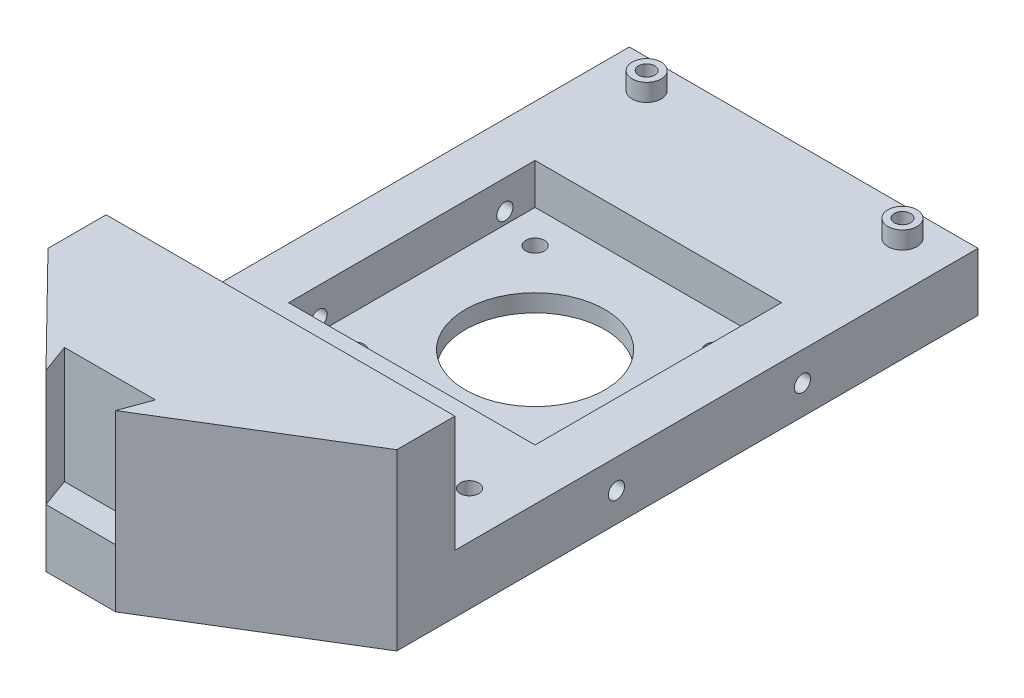
from build123d import *

# Parameters (mm, degrees)
EXTRUDE_1_DEPTH             = 30
SKETCH_2_W                  = 90
SKETCH_2_H                  = 20
CUT_EXTRUDE_1_DEPTH         = 61
SKETCH_3_W                  = 42.4
SKETCH_3_H                  = 42.4
CUT_EXTRUDE_2_DEPTH         = 7
SKETCH_4_W                  = 2.5
SKETCH_4_H                  = 3
SKETCH_5_W                  = 2.5
SKETCH_5_H                  = 3
HOLE_WIZARD_24_0_24_1_D     = 24
HOLE_WIZARD_24_0_24_1_DEPTH = 3
HOLE_WIZARD_3_2_3_2_1_D     = 3.2
HOLE_WIZARD_3_2_3_2_1_DEPTH = 3
HOLE_WIZARD_2_8_2_8_1_D     = 2.8
HOLE_WIZARD_2_8_2_8_1_DEPTH = 13
HOLE_WIZARD_3_2_3_2_2_D     = 3.2
HOLE_WIZARD_3_2_3_2_2_DEPTH = 10
HOLE_WIZARD_2_8_2_8_2_D     = 2.8
HOLE_WIZARD_2_8_2_8_2_DEPTH = 8.8
HOLE_WIZARD_2_8_2_8_3_D     = 2.8
HOLE_WIZARD_2_8_2_8_3_DEPTH = 8.8
EXTRUDE_2_DEPTH             = 10


with BuildPart() as part:
    # 草图1 → 凸台-拉伸1 (new body)
    with BuildSketch(Plane(origin=(0, 30, 0), x_dir=(1, 0, 0), z_dir=(0, 1, 0))):
        Polygon((-53.759164819, 38.577872891), (-53.759164819, -61.422127109), (-35.759164819, -79.767511878), (-37.57901599, -74.767511878), (-21.939313647, -74.767511878), (-23.759164819, -79.767511878), (6.240835181, -61.422127109), (6.240835181, 38.577872891), align=None)
    extrude(amount=-EXTRUDE_1_DEPTH)

    # 草图2 → 切除-拉伸1 (cut, through all)
    with BuildSketch(Plane.ZY.offset(53.759164819)):
        with Locations((6.422127109, 20)):
            Rectangle(SKETCH_2_W, SKETCH_2_H)
    extrude(amount=-CUT_EXTRUDE_1_DEPTH, mode=Mode.SUBTRACT)

    # 草图3 → 切除-拉伸2 (cut)
    with BuildSketch(Plane(origin=(0, 10, 0), x_dir=(-1, 0, 0), z_dir=(0, 1, 0))):
        with Locations((23.759164819, 7.622127109)):
            Rectangle(SKETCH_3_W, SKETCH_3_H)
    extrude(amount=-CUT_EXTRUDE_2_DEPTH, mode=Mode.SUBTRACT)

    # 草图4 → 旋转1 (revolve)
    with BuildSketch(Plane.XY.offset(-33.577872891)):
        with Locations((-44.509164819, 11.5)):
            Rectangle(SKETCH_4_W, SKETCH_4_H)
    revolve(axis=Axis((-45.759164819, 13, -33.577872891), (0, -1, 0)))

    # 草图5 → 旋转2 (revolve)
    with BuildSketch(Plane.XY.offset(-33.577872891)):
        with Locations((-0.509164819, 11.5)):
            Rectangle(SKETCH_5_W, SKETCH_5_H)
    revolve(axis=Axis((-1.759164819, 13, -33.577872891), (0, -1, 0)))

    # Ø24.0 (24) 直径孔1
    with Locations(Plane(origin=(0, 3, 0), x_dir=(1, 0, 0), z_dir=(0, 1, 0))):
        with Locations((-23.759164819, -7.622127109)):
            Hole(HOLE_WIZARD_24_0_24_1_D / 2, depth=HOLE_WIZARD_24_0_24_1_DEPTH)

    # Ø3.2 (3.2) 直径孔1
    with Locations(Plane(origin=(0, 3, 0), x_dir=(1, 0, 0), z_dir=(0, 1, 0))):
        with Locations((-8.259164819, -23.122127109), (-39.259164819, 7.877872891), (-8.259164819, 7.877872891), (-39.259164819, -23.122127109)):
            Hole(HOLE_WIZARD_3_2_3_2_1_D / 2, depth=HOLE_WIZARD_3_2_3_2_1_DEPTH)

    # Ø2.8 (2.8) 直径孔1
    with Locations(Plane(origin=(0, 13, 0), x_dir=(1, 0, 0), z_dir=(0, 1, 0))):
        with Locations((-45.759164819, 33.577872891), (-1.759164819, 33.577872891)):
            Hole(HOLE_WIZARD_2_8_2_8_1_D / 2, depth=HOLE_WIZARD_2_8_2_8_1_DEPTH)

    # Ø3.2 (3.2) 直径孔2
    with Locations(Plane(origin=(0, 10, 0), x_dir=(1, 0, 0), z_dir=(0, 1, 0))):
        with Locations((-45.759164819, -40.922127109), (-1.759164819, -40.922127109)):
            Hole(HOLE_WIZARD_3_2_3_2_2_D / 2, depth=HOLE_WIZARD_3_2_3_2_2_DEPTH)

    # Ø2.8 (2.8) 直径孔2
    with Locations(Plane.ZY.offset(53.759164819)):
        with Locations((-8.377872891, 5), (23.622127109, 5)):
            Hole(HOLE_WIZARD_2_8_2_8_2_D / 2, depth=HOLE_WIZARD_2_8_2_8_2_DEPTH)

    # Ø2.8 (2.8) 直径孔3
    with Locations(Plane.ZY.offset(2.559164819)):
        with Locations((-8.377872891, 5), (23.622127109, 5)):
            Hole(HOLE_WIZARD_2_8_2_8_3_D / 2, depth=HOLE_WIZARD_2_8_2_8_3_DEPTH)

    # 草图18 → 凸台-拉伸2 (add)
    with BuildSketch(Plane.XZ):
        Polygon((-35.759164819, 79.767511878), (-37.57901599, 74.767511878), (-21.939313647, 74.767511878), (-23.759164819, 79.767511878), align=None)
    extrude(amount=-EXTRUDE_2_DEPTH)


solid = part.part
